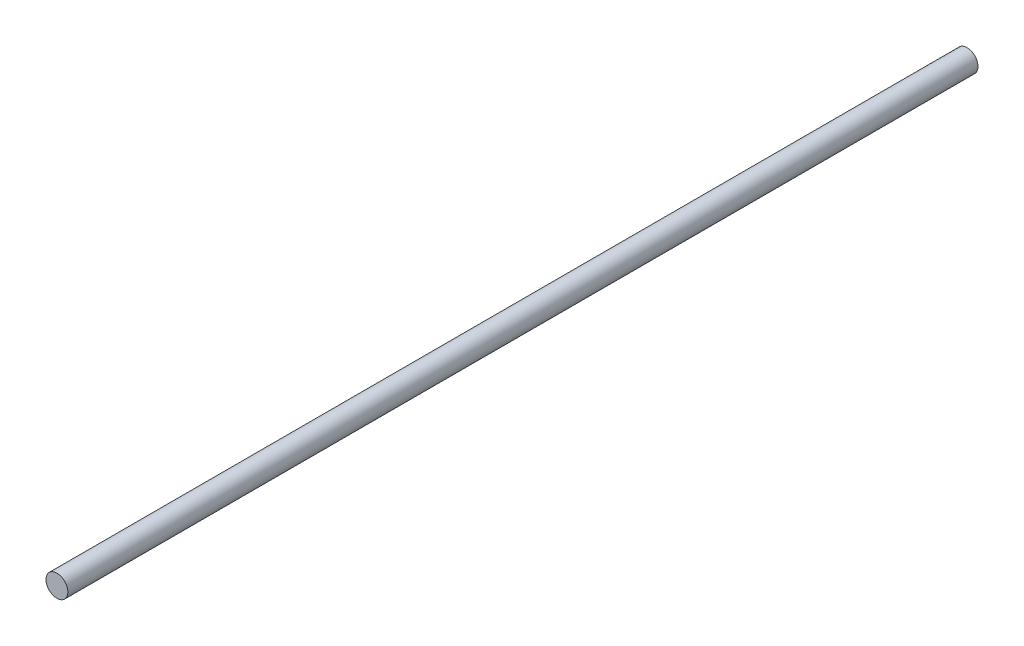
from build123d import *

# Parameters (mm, degrees)
SKETCH1_R           = 3
BOSS_EXTRUDE1_DEPTH = 125


with BuildPart() as part:
    # Sketch1 → Boss-Extrude1 (new body, symmetric)
    with BuildSketch(Plane.XY):
        Circle(SKETCH1_R)
    extrude(amount=BOSS_EXTRUDE1_DEPTH, both=True)


solid = part.part
